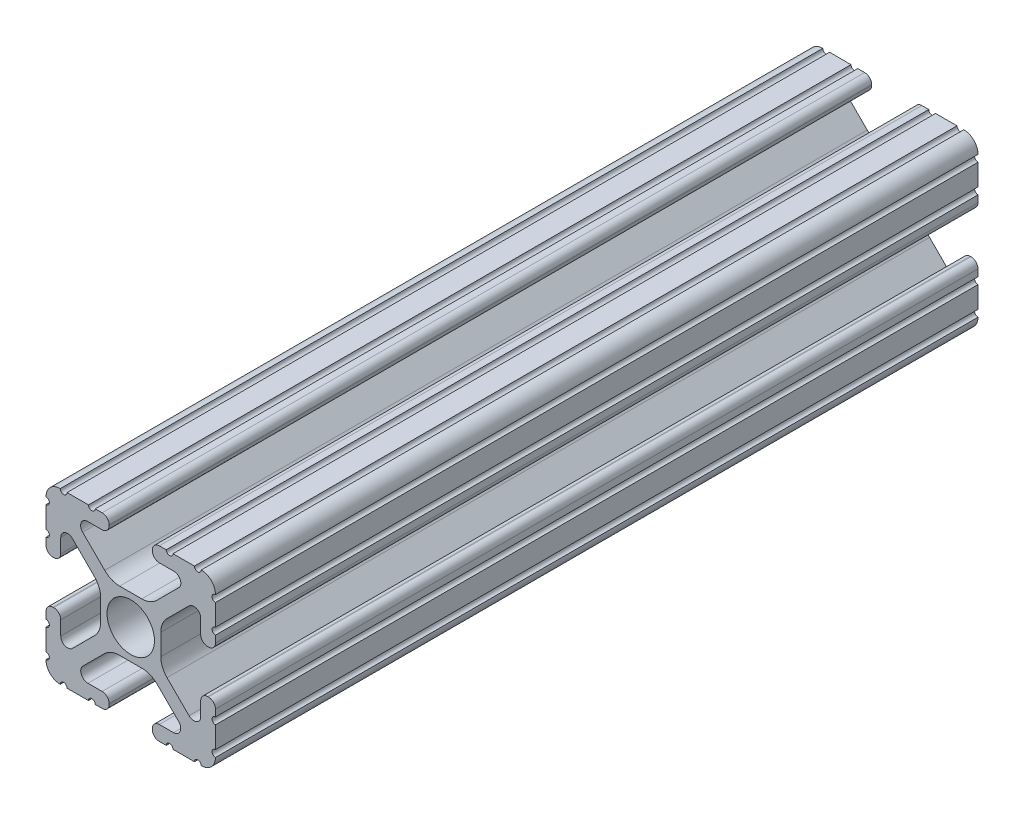
from build123d import *

# Parameters (mm, degrees)
SKETCH1_R           = 3.556
BOSS_EXTRUDE1_DEPTH = 57.15


with BuildPart() as part:
    # Sketch1 → Boss-Extrude1 (new body, symmetric)
    with BuildSketch(Plane.XY):
        with BuildLine():
            Line((-7.179650497, -8.645192506), (-3.952270251, -5.423690499))
            ThreePointArc((-3.952270251, -5.423690499), (-2.922936451, -4.736929036), (-1.709253557, -4.4958))
            Line((-1.709253557, -4.4958), (1.709253557, -4.4958))
            ThreePointArc((1.709253557, -4.4958), (2.922936451, -4.736929036), (3.952270251, -5.423690499))
            Line((3.952270251, -5.423690499), (7.179650497, -8.645192506))
            ThreePointArc((7.179650497, -8.645192506), (7.41473083, -9.822813117), (6.416408329, -10.4902))
            Line((6.416408329, -10.4902), (4.287512407, -10.4902))
            ThreePointArc((4.287512407, -10.4902), (3.54574862, -10.79744862), (3.2385, -11.539212407))
            Line((3.2385, -11.539212407), (3.2385, -11.650987593))
            ThreePointArc((3.2385, -11.650987593), (3.54574862, -12.39275138), (4.287512407, -12.7))
            Line((4.287512407, -12.7), (5.317126718, -12.7))
            ThreePointArc((5.317126718, -12.7), (5.825126718, -12.192), (6.333126718, -12.7))
            Line((6.333126718, -12.7), (9.550443118, -12.7))
            ThreePointArc((9.550443118, -12.7), (10.058366869, -12.192000006), (10.566443095, -12.699847501))
            ThreePointArc((10.566443095, -12.699847501), (12.082537762, -12.08250727), (12.699846982, -10.566399977))
            ThreePointArc((12.699846982, -10.566399977), (12.192000006, -10.058323491), (12.7, -9.5504))
            Line((12.7, -9.5504), (12.7, -6.3330836))
            ThreePointArc((12.7, -6.3330836), (12.192, -5.8250836), (12.7, -5.3170836))
            Line((12.7, -5.3170836), (12.7, -4.287469289))
            ThreePointArc((12.7, -4.287469289), (12.39275138, -3.545705502), (11.650987593, -3.238456882))
            Line((11.650987593, -3.238456882), (11.539212407, -3.238456882))
            ThreePointArc((11.539212407, -3.238456882), (10.79744862, -3.545705502), (10.4902, -4.287469289))
            Line((10.4902, -4.287469289), (10.4902, -6.402089023))
            ThreePointArc((10.4902, -6.402089023), (9.856505071, -7.351067942), (8.737131347, -7.129408934))
            Line((8.737131347, -7.129408934), (5.441005833, -3.840816462))
            ThreePointArc((5.441005833, -3.840816462), (4.750877967, -2.809883091), (4.5085, -1.593185507))
            Line((4.5085, -1.593185507), (4.5085, 1.593185507))
            ThreePointArc((4.5085, 1.593185507), (4.750877967, 2.809883091), (5.441005833, 3.840816462))
            Line((5.441005833, 3.840816462), (8.737131347, 7.129408934))
            ThreePointArc((8.737131347, 7.129408934), (9.856505071, 7.351067942), (10.4902, 6.402089023))
            Line((10.4902, 6.402089023), (10.4902, 4.287469289))
            ThreePointArc((10.4902, 4.287469289), (10.79744862, 3.545705502), (11.539212407, 3.238456882))
            Line((11.539212407, 3.238456882), (11.650987593, 3.238456882))
            ThreePointArc((11.650987593, 3.238456882), (12.39275138, 3.545705502), (12.7, 4.287469289))
            Line((12.7, 4.287469289), (12.7, 5.3170836))
            ThreePointArc((12.7, 5.3170836), (12.192, 5.8250836), (12.7, 6.3330836))
            Line((12.7, 6.3330836), (12.7, 9.5504))
            ThreePointArc((12.7, 9.5504), (12.192000006, 10.058323491), (12.699846982, 10.566399977))
            ThreePointArc((12.699846982, 10.566399977), (12.082537762, 12.08250727), (10.566443095, 12.699847501))
            ThreePointArc((10.566443095, 12.699847501), (10.058366869, 12.192000006), (9.550443118, 12.7))
            Line((9.550443118, 12.7), (6.333126718, 12.7))
            ThreePointArc((6.333126718, 12.7), (5.825126718, 12.192), (5.317126718, 12.7))
            Line((5.317126718, 12.7), (4.287512407, 12.7))
            ThreePointArc((4.287512407, 12.7), (3.54574862, 12.39275138), (3.2385, 11.650987593))
            Line((3.2385, 11.650987593), (3.2385, 11.539212407))
            ThreePointArc((3.2385, 11.539212407), (3.54574862, 10.79744862), (4.287512407, 10.4902))
            Line((4.287512407, 10.4902), (6.476788598, 10.4902))
            ThreePointArc((6.476788598, 10.4902), (7.432222385, 9.85140422), (7.207036008, 8.724370562))
            Line((7.207036008, 8.724370562), (3.898272566, 5.423169045))
            ThreePointArc((3.898272566, 5.423169045), (2.869120213, 4.736787962), (1.655778399, 4.4958))
            Line((1.655778399, 4.4958), (-1.655778399, 4.4958))
            ThreePointArc((-1.655778399, 4.4958), (-2.869120213, 4.736787962), (-3.898272566, 5.423169045))
            Line((-3.898272566, 5.423169045), (-7.207036008, 8.724370562))
            ThreePointArc((-7.207036008, 8.724370562), (-7.432222385, 9.85140422), (-6.476788598, 10.4902))
            Line((-6.476788598, 10.4902), (-4.287512407, 10.4902))
            ThreePointArc((-4.287512407, 10.4902), (-3.54574862, 10.79744862), (-3.2385, 11.539212407))
            Line((-3.2385, 11.539212407), (-3.2385, 11.650987593))
            ThreePointArc((-3.2385, 11.650987593), (-3.54574862, 12.39275138), (-4.287512407, 12.7))
            Line((-4.287512407, 12.7), (-5.317126718, 12.7))
            ThreePointArc((-5.317126718, 12.7), (-5.825126718, 12.192), (-6.333126718, 12.7))
            Line((-6.333126718, 12.7), (-9.550443118, 12.7))
            ThreePointArc((-9.550443118, 12.7), (-10.058366869, 12.192000006), (-10.566443095, 12.699847501))
            ThreePointArc((-10.566443095, 12.699847501), (-12.082537762, 12.08250727), (-12.699846982, 10.566399977))
            ThreePointArc((-12.699846982, 10.566399977), (-12.192000006, 10.058323491), (-12.7, 9.5504))
            Line((-12.7, 9.5504), (-12.7, 6.3330836))
            ThreePointArc((-12.7, 6.3330836), (-12.192, 5.8250836), (-12.7, 5.3170836))
            Line((-12.7, 5.3170836), (-12.7, 4.287469289))
            ThreePointArc((-12.7, 4.287469289), (-12.39275138, 3.545705502), (-11.650987593, 3.238456882))
            Line((-11.650987593, 3.238456882), (-11.539212407, 3.238456882))
            ThreePointArc((-11.539212407, 3.238456882), (-10.79744862, 3.545705502), (-10.4902, 4.287469289))
            Line((-10.4902, 4.287469289), (-10.4902, 6.402089023))
            ThreePointArc((-10.4902, 6.402089023), (-9.856505071, 7.351067942), (-8.737131347, 7.129408934))
            Line((-8.737131347, 7.129408934), (-5.441005833, 3.840816462))
            ThreePointArc((-5.441005833, 3.840816462), (-4.750877967, 2.809883091), (-4.5085, 1.593185507))
            Line((-4.5085, 1.593185507), (-4.5085, -1.593185507))
            ThreePointArc((-4.5085, -1.593185507), (-4.750877967, -2.809883091), (-5.441005833, -3.840816462))
            Line((-5.441005833, -3.840816462), (-8.737131347, -7.129408934))
            ThreePointArc((-8.737131347, -7.129408934), (-9.856505071, -7.351067942), (-10.4902, -6.402089023))
            Line((-10.4902, -6.402089023), (-10.4902, -4.287469289))
            ThreePointArc((-10.4902, -4.287469289), (-10.79744862, -3.545705502), (-11.539212407, -3.238456882))
            Line((-11.539212407, -3.238456882), (-11.650987593, -3.238456882))
            ThreePointArc((-11.650987593, -3.238456882), (-12.39275138, -3.545705502), (-12.7, -4.287469289))
            Line((-12.7, -4.287469289), (-12.7, -5.3170836))
            ThreePointArc((-12.7, -5.3170836), (-12.192, -5.8250836), (-12.7, -6.3330836))
            Line((-12.7, -6.3330836), (-12.7, -9.5504))
            ThreePointArc((-12.7, -9.5504), (-12.192000006, -10.058323491), (-12.699846982, -10.566399977))
            ThreePointArc((-12.699846982, -10.566399977), (-12.082537762, -12.08250727), (-10.566443095, -12.699847501))
            ThreePointArc((-10.566443095, -12.699847501), (-10.058366869, -12.192000006), (-9.550443118, -12.7))
            Line((-9.550443118, -12.7), (-6.333126718, -12.7))
            ThreePointArc((-6.333126718, -12.7), (-5.825126718, -12.192), (-5.317126718, -12.7))
            Line((-5.317126718, -12.7), (-4.287512407, -12.7))
            ThreePointArc((-4.287512407, -12.7), (-3.54574862, -12.39275138), (-3.2385, -11.650987593))
            Line((-3.2385, -11.650987593), (-3.2385, -11.539212407))
            ThreePointArc((-3.2385, -11.539212407), (-3.54574862, -10.79744862), (-4.287512407, -10.4902))
            Line((-4.287512407, -10.4902), (-6.416408329, -10.4902))
            ThreePointArc((-6.416408329, -10.4902), (-7.41473083, -9.822813117), (-7.179650497, -8.645192506))
        make_face()
        Circle(SKETCH1_R, mode=Mode.SUBTRACT)
    extrude(amount=BOSS_EXTRUDE1_DEPTH, both=True)


solid = part.part
